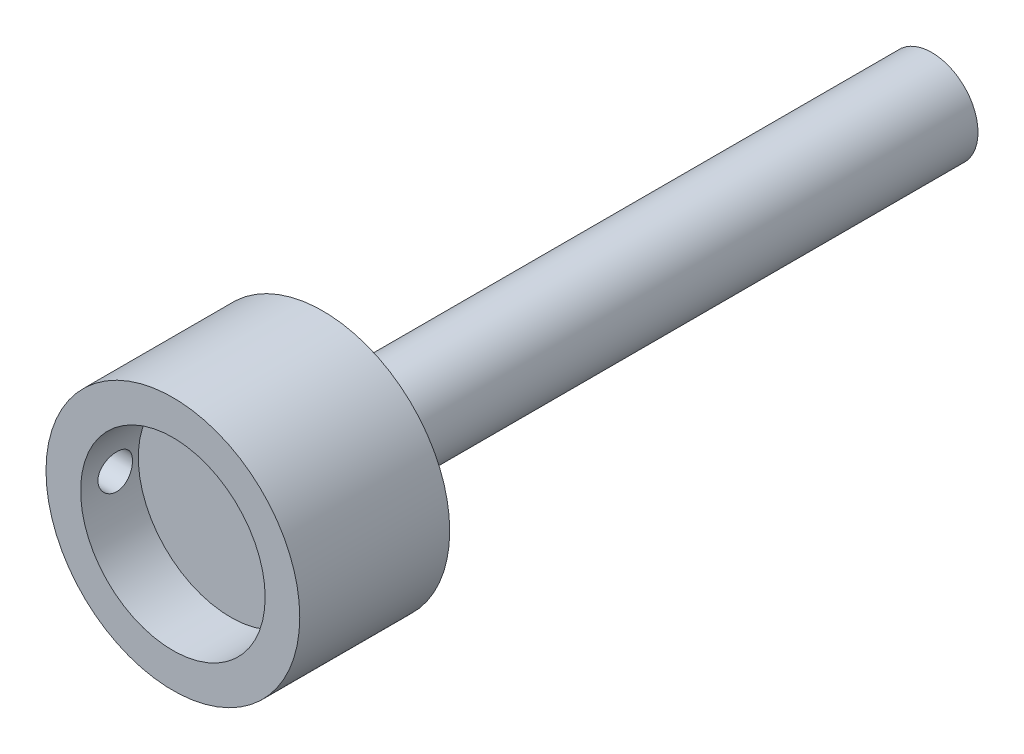
from build123d import *

# Parameters (mm, degrees)
CROQUIS1_R              = 11
SALIENTE_EXTRUIR1_DEPTH = 13
CROQUIS2_R              = 8
CORTAR_EXTRUIR1_DEPTH   = 5
CROQUIS3_R              = 1.5
CORTAR_EXTRUIR2_DEPTH   = 15
CROQUIS4_R              = 4
SALIENTE_EXTRUIR2_DEPTH = 52.8


with BuildPart() as part:
    # Croquis1 → Saliente-Extruir1 (new body)
    with BuildSketch(Plane.XY):
        Circle(CROQUIS1_R)
    extrude(amount=SALIENTE_EXTRUIR1_DEPTH)

    # Croquis2 → Cortar-Extruir1 (cut)
    with BuildSketch(Plane.XY.offset(13)):
        Circle(CROQUIS2_R)
    extrude(amount=-CORTAR_EXTRUIR1_DEPTH, mode=Mode.SUBTRACT)

    # Croquis3 → Cortar-Extruir2 (cut)
    with BuildSketch(Plane(origin=(0, 0, 0), x_dir=(0, 0, -1), z_dir=(1, 0, 0))):
        with Locations((-10, 0)):
            Circle(CROQUIS3_R)
    extrude(amount=-CORTAR_EXTRUIR2_DEPTH, mode=Mode.SUBTRACT)

    # Croquis4 → Saliente-Extruir2 (add)
    with BuildSketch(Plane(origin=(0, 0, 0), x_dir=(-1, 0, 0), z_dir=(0, 0, -1))):
        Circle(CROQUIS4_R)
    extrude(amount=SALIENTE_EXTRUIR2_DEPTH)


solid = part.part
